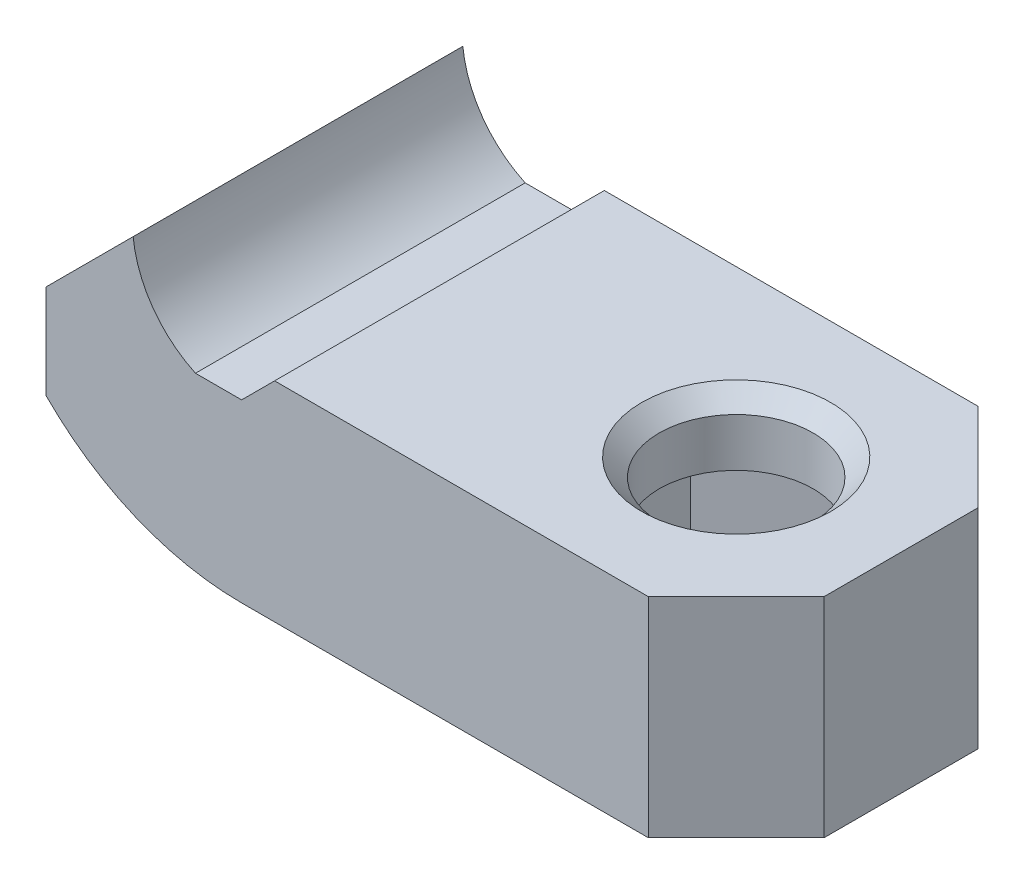
from build123d import *

# Parameters (mm, degrees)
SALIENTE_EXTRUIR1_DEPTH = 7.5
SALIENTE_EXTRUIR2_DEPTH = 15
CROQUIS7_R              = 3.5
CORTAR_EXTRUIR4_DEPTH   = 10.5
CORTAR_EXTRUIR5_START   = -3
CORTAR_EXTRUIR5_DEPTH   = 10
CHAFL_N4_SIZE           = 4
CHAFL_N5_SIZE           = 0.8


with BuildPart() as part:
    # Croquis1 → Saliente-Extruir1 (new body, symmetric)
    with BuildSketch(Plane.XY):
        with BuildLine():
            Line((-8.9, 4), (-4.936786437, 7.963213563))
            ThreePointArc((-4.936786437, 7.963213563), (-4.038051049, 5.609646436), (-2.1, 4))
            Line((-2.1, 4), (0, 4))
            Line((0, 4), (0, -4))
            ThreePointArc((0, -4), (-4.823611651, -3.031815583), (-8.9, -0.277243303))
            Line((-8.9, -0.277243303), (-8.9, 4))
        make_face()
    extrude(amount=SALIENTE_EXTRUIR1_DEPTH, both=True)

    # Croquis6 → Saliente-Extruir2 (add, through all)
    with BuildSketch(Plane(origin=(0, 0, -7.5), x_dir=(-1, 0, 0), z_dir=(0, 0, -1))):
        Polygon((0, 4), (-1.5, 5.5), (-22.5, 5.5), (-22.5, -4), (0, -4), align=None)
    extrude(amount=-SALIENTE_EXTRUIR2_DEPTH)

    # Croquis7 → Cortar-Extruir4 (cut, through all)
    with BuildSketch(Plane(origin=(0, 5.5, 0), x_dir=(1, 0, 0), z_dir=(0, 1, 0))):
        with Locations((15, 0)):
            Circle(CROQUIS7_R)
    extrude(amount=-CORTAR_EXTRUIR4_DEPTH, mode=Mode.SUBTRACT)

    # Croquis8 → Cortar-Extruir5 (cut)
    with BuildSketch(Plane(origin=(0, 5.5, 0), x_dir=(1, 0, 0), z_dir=(0, 1, 0)).offset(CORTAR_EXTRUIR5_START)):
        Polygon((15, 5.658032638), (10.1, 2.829016319), (10.1, -2.829016319), (15, -5.658032638), (19.9, -2.829016319), (19.9, 2.829016319), align=None)
    extrude(amount=-CORTAR_EXTRUIR5_DEPTH, mode=Mode.SUBTRACT)

    # Chaflán4
    chafl_n4_edges = [part.edges().sort_by_distance(p)[0] for p in [
        (22.5, 0.75, 7.5),
        (22.5, 0.75, -7.5),
    ]]
    chamfer(chafl_n4_edges, length=CHAFL_N4_SIZE)

    # Chaflán5
    chafl_n5_edges = [part.edges().sort_by_distance(p)[0] for p in [
        (11.5, 5.5, 0),
        (12.55, -4, -4.243524479),
        (10.1, -4, 0),
        (12.55, -4, 4.243524479),
        (17.45, -4, 4.243524479),
        (19.9, -4, 0),
        (17.45, -4, -4.243524479),
    ]]
    chamfer(chafl_n5_edges, length=CHAFL_N5_SIZE)


solid = part.part
